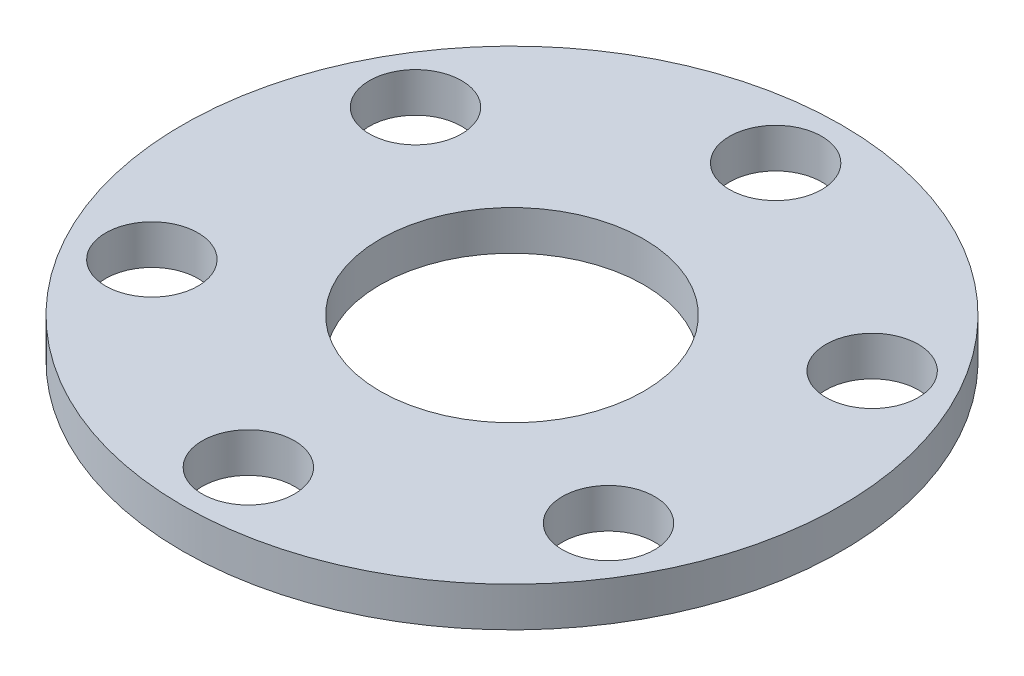
from build123d import *

# Parameters (mm, degrees)
SKETCH1_R           = 12.5
SKETCH1_R_2         = 5
BOSS_EXTRUDE1_DEPTH = 1.5
SKETCH2_R           = 1.75
CUT_EXTRUDE1_DEPTH  = 2.5
CIRPATTERN1_COUNT   = 6


with BuildPart() as part:
    # Sketch1 → Boss-Extrude1 (new body)
    with BuildSketch(Plane(origin=(0, 0, 0), x_dir=(1, 0, 0), z_dir=(0, 1, 0))):
        Circle(SKETCH1_R)
        Circle(SKETCH1_R_2, mode=Mode.SUBTRACT)
    extrude(amount=BOSS_EXTRUDE1_DEPTH)

    # Sketch2 → Cut-Extrude1 (cut, through all)
    with BuildSketch(Plane(origin=(0, 0, 0), x_dir=(1, 0, 0), z_dir=(0, 1, 0))):
        with Locations((0, 10)):
            Circle(SKETCH2_R)
    cut_extrude1 = extrude(amount=CUT_EXTRUDE1_DEPTH, mode=Mode.SUBTRACT)

    # CirPattern1: Cut-Extrude1 ×6 about axis
    cirpattern1_axis = Axis((0, 0, 0), (0, 1, 0))
    for i in range(1, CIRPATTERN1_COUNT):
        add(cut_extrude1.rotate(cirpattern1_axis, i * 360 / CIRPATTERN1_COUNT), mode=Mode.SUBTRACT)


solid = part.part
